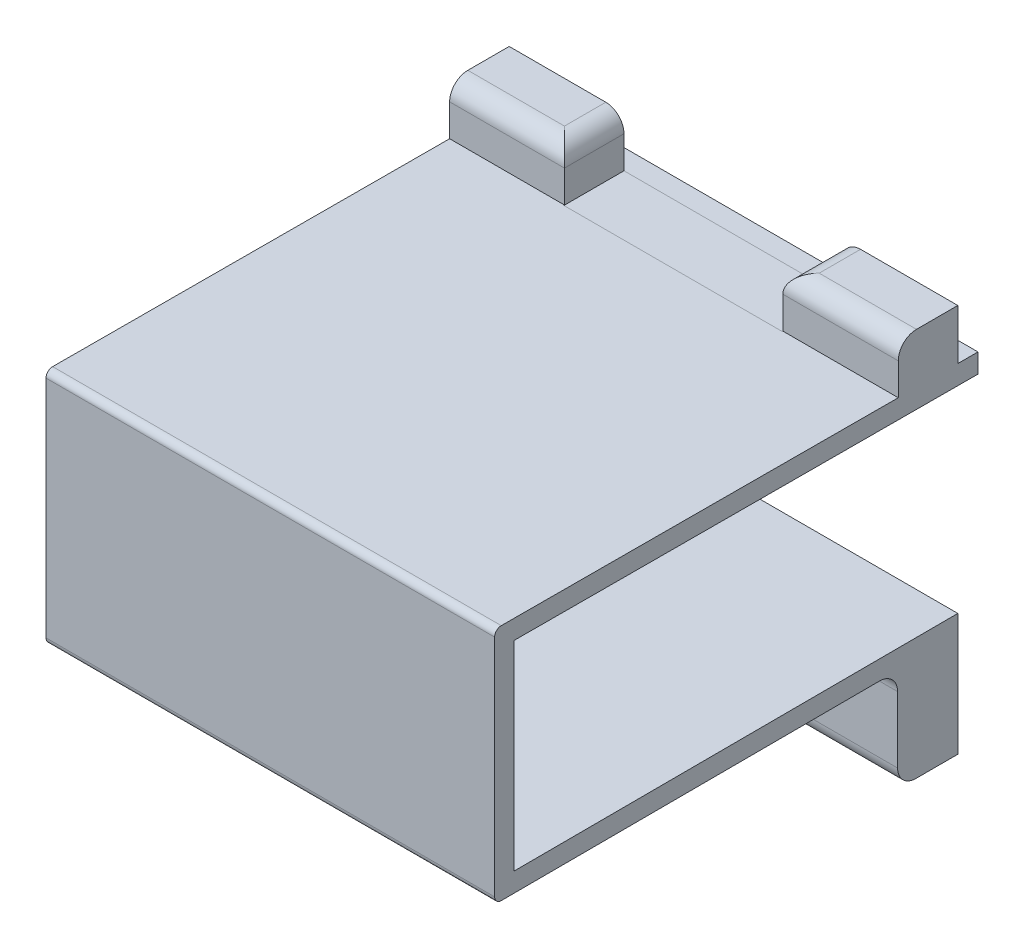
from build123d import *

# Parameters (mm, degrees)
AUFSATZ_LINEAR_AUSTRAGEN1_DEPTH = 67.8
SKIZZE3_W                       = 33
SKIZZE3_H                       = 7.6
SKIZZE3_H_2                     = 16.35
SCHNITT_LINEAR_AUSTRAGEN1_DEPTH = 9.1
SKIZZE4_W                       = 2.75
SKIZZE4_H                       = 30.2
AUFSATZ_LINEAR_AUSTRAGEN2_DEPTH = 66.1
VERRUNDUNG1_R                   = 2.75
VERRUNDUNG3_R                   = 1
SCHNITT_LINEAR_AUSTRAGEN2_DEPTH = 35


with BuildPart() as part:
    # Skizze1 → Aufsatz-Linear austragen1 (new body)
    with BuildSketch(Plane(origin=(0, 0, 0), x_dir=(0, 0, -1), z_dir=(1, 0, 0))):
        Polygon((-67.1, 29.991702941), (3.049987553, 29.791286266), (3.049987553, 32.695849754), (0, 32.704563488), (0, 40.304563488), (-9, 40.304563488), (-9, 32.725724599), (-70, 32.9), (-70, -3.1), (-9.1, -2.926010297), (-9.1, -18.44), (0, -18.44), (0, 0), (-67.1, -0.191702941), align=None)
    extrude(amount=-AUFSATZ_LINEAR_AUSTRAGEN1_DEPTH)

    # Skizze3 → Schnitt-Linear austragen1 (cut)
    with BuildSketch(Plane.XY):
        with Locations((-33.95, 36.504563488)):
            Rectangle(SKIZZE3_W, SKIZZE3_H)
        with Locations((-33.95, -10.265)):
            Rectangle(SKIZZE3_W, SKIZZE3_H_2)
    extrude(amount=SCHNITT_LINEAR_AUSTRAGEN1_DEPTH, mode=Mode.SUBTRACT)

    # Skizze4 → Aufsatz-Linear austragen2 (add)
    with BuildSketch(Plane.XY.offset(1)):
        with Locations((-33.625, 15.1)):
            Rectangle(SKIZZE4_W, SKIZZE4_H)
    extrude(amount=AUFSATZ_LINEAR_AUSTRAGEN2_DEPTH)

    # Verrundung1
    verrundung1_edges = [part.edges().sort_by_distance(p)[0] for p in [
        (-59.125, -18.44, 9.1),
        (-59.125, -2.926010297, 9.1),
        (-59.125, 40.304563488, 9),
        (-8.725, 40.304563488, 9),
        (-17.45, 40.304563488, 4.5),
        (-50.45, 40.304563488, 4.5),
        (-8.725, -2.926010297, 9.1),
        (-8.725, -18.44, 9.1),
        (-17.45, -18.44, 4.55),
        (-50.45, -18.44, 4.55),
    ]]
    fillet(verrundung1_edges, radius=VERRUNDUNG1_R)

    # Verrundung3
    verrundung3_edges = [part.edges().sort_by_distance(p)[0] for p in [
        (-33.9, -3.1, 70),
        (-33.9, 32.9, 70),
    ]]
    fillet(verrundung3_edges, radius=VERRUNDUNG3_R)

    # Skizze6 → Schnitt-Linear austragen2 (cut)
    with BuildSketch(Plane(origin=(0, 0, 0), x_dir=(0, 0, -1), z_dir=(1, 0, 0))):
        Polygon((-67.1, 29.991702941), (-34, 29.897137109), (-34, -0.097137109), (-67.1, -0.191702941), align=None)
    extrude(amount=-SCHNITT_LINEAR_AUSTRAGEN2_DEPTH, mode=Mode.SUBTRACT)


solid = part.part
